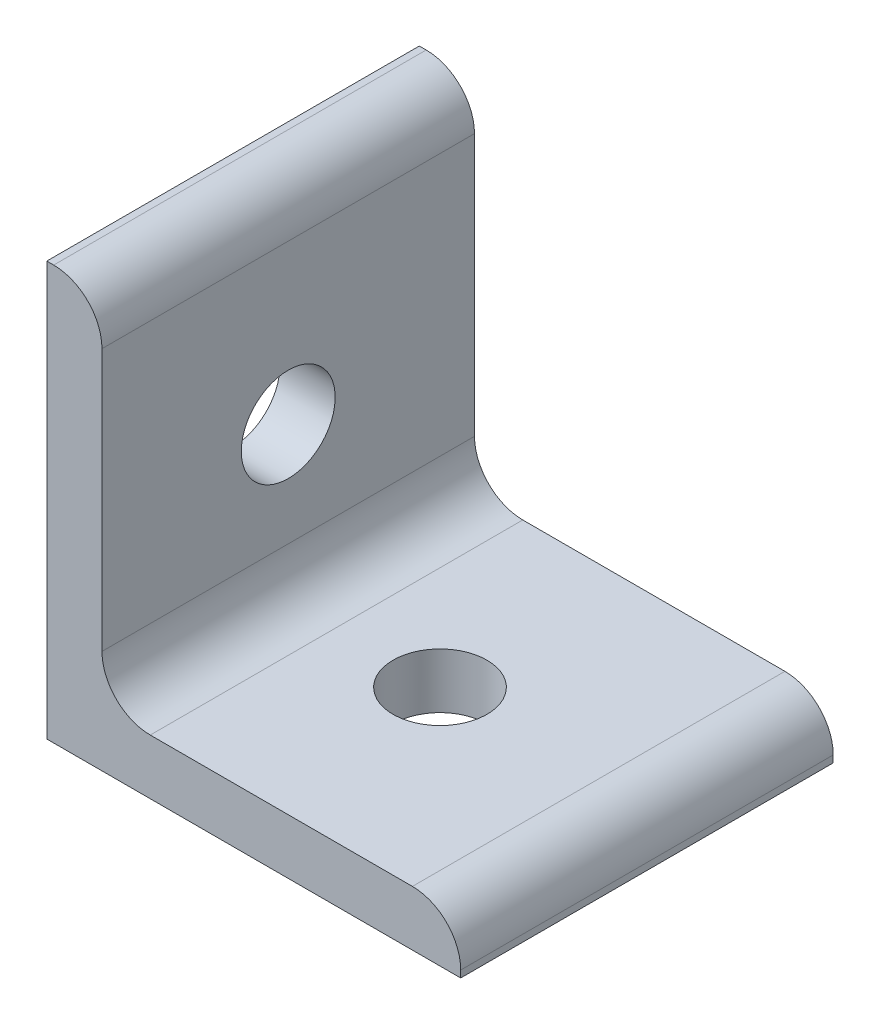
from build123d import *

# Parameters (mm, degrees)
BOSS_EXTRUDE1_DEPTH = 13.5
SKETCH4_R           = 3.4036
CUT_EXTRUDE3_DEPTH  = 10
SKETCH5_R           = 3.4036
CUT_EXTRUDE4_DEPTH  = 10


with BuildPart() as part:
    # Sketch1 → Boss-Extrude1 (new body, symmetric)
    with BuildSketch(Plane.XY):
        with BuildLine():
            Line((0, 0), (30, 0))
            Line((30, 0), (30, 0.5))
            ThreePointArc((30, 0.5), (28.974873734, 2.974873734), (26.5, 4))
            Line((26.5, 4), (7.5, 4))
            ThreePointArc((7.5, 4), (5.025126266, 5.025126266), (4, 7.5))
            Line((4, 7.5), (4, 26.5))
            ThreePointArc((4, 26.5), (2.974873734, 28.974873734), (0.5, 30))
            Line((0.5, 30), (0, 30))
            Line((0, 30), (0, 0))
        make_face()
    extrude(amount=BOSS_EXTRUDE1_DEPTH, both=True)

    # Sketch4 → Cut-Extrude3 (cut)
    with BuildSketch(Plane.ZY):
        with Locations((0, 15)):
            Circle(SKETCH4_R)
    extrude(amount=-CUT_EXTRUDE3_DEPTH, mode=Mode.SUBTRACT)

    # Sketch5 → Cut-Extrude4 (cut)
    with BuildSketch(Plane.XZ):
        with Locations((15, 0)):
            Circle(SKETCH5_R)
    extrude(amount=-CUT_EXTRUDE4_DEPTH, mode=Mode.SUBTRACT)


solid = part.part
